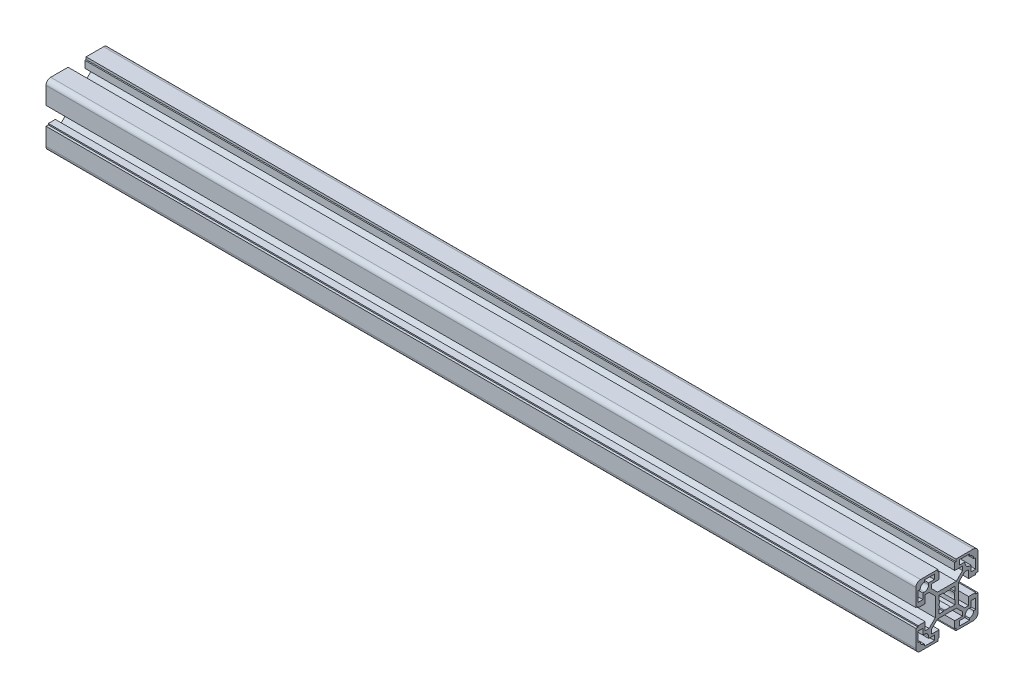
from build123d import *

# Parameters (mm, degrees)
BR_EXTRUDE_DEPTH      = 280
BR_EXTRUDE_DEPTH_BACK = 280


with BuildPart() as part:
    # Sketch2 → BR_Extrude (new body, two sides)
    with BuildSketch(Plane(origin=(0, 0, 0), x_dir=(0, 0, -1), z_dir=(1, 0, 0))) as br_extrude_sk:
        with BuildLine():
            Line((-10.05, 11.464213562), (-10.05, 14))
            Line((-10.05, 14), (-5, 14))
            Line((-5, 14), (-5, 18.5))
            Line((-5, 18.5), (-5.8, 18.5))
            Line((-5.8, 18.5), (-5.8, 20))
            Line((-5.8, 20), (-17, 20))
            ThreePointArc((-17, 20), (-19.121320344, 19.121320344), (-20, 17))
            Line((-20, 17), (-20, 5.8))
            Line((-20, 5.8), (-18.5, 5.8))
            Line((-18.5, 5.8), (-18.5, 5))
            Line((-18.5, 5), (-14, 5))
            Line((-14, 5), (-14, 10.05))
            Line((-14, 10.05), (-11.464213562, 10.05))
            Line((-11.464213562, 10.05), (-7.5, 6.085786438))
            Line((-7.5, 6.085786438), (-7.5, -6.085786438))
            Line((-7.5, -6.085786438), (-11.464213562, -10.05))
            Line((-11.464213562, -10.05), (-14, -10.05))
            Line((-14, -10.05), (-14, -5))
            Line((-14, -5), (-18.5, -5))
            Line((-18.5, -5), (-18.5, -5.8))
            Line((-18.5, -5.8), (-20, -5.8))
            Line((-20, -5.8), (-20, -17))
            ThreePointArc((-20, -17), (-19.121320344, -19.121320344), (-17, -20))
            Line((-17, -20), (-5.8, -20))
            Line((-5.8, -20), (-5.8, -18.5))
            Line((-5.8, -18.5), (-5, -18.5))
            Line((-5, -18.5), (-5, -14))
            Line((-5, -14), (-10.05, -14))
            Line((-10.05, -14), (-10.05, -11.464213562))
            Line((-10.05, -11.464213562), (-6.085786438, -7.5))
            Line((-6.085786438, -7.5), (6.085786438, -7.5))
            Line((6.085786438, -7.5), (10.05, -11.464213562))
            Line((10.05, -11.464213562), (10.05, -14))
            Line((10.05, -14), (5, -14))
            Line((5, -14), (5, -18.5))
            Line((5, -18.5), (5.8, -18.5))
            Line((5.8, -18.5), (5.8, -20))
            Line((5.8, -20), (17, -20))
            ThreePointArc((17, -20), (19.121320344, -19.121320344), (20, -17))
            Line((20, -17), (20, -5.8))
            Line((20, -5.8), (18.5, -5.8))
            Line((18.5, -5.8), (18.5, -5))
            Line((18.5, -5), (14, -5))
            Line((14, -5), (14, -10.05))
            Line((14, -10.05), (11.464213562, -10.05))
            Line((11.464213562, -10.05), (7.5, -6.085786438))
            Line((7.5, -6.085786438), (7.5, 6.085786438))
            Line((7.5, 6.085786438), (11.464213562, 10.05))
            Line((11.464213562, 10.05), (14, 10.05))
            Line((14, 10.05), (14, 5))
            Line((14, 5), (18.5, 5))
            Line((18.5, 5), (18.5, 5.8))
            Line((18.5, 5.8), (20, 5.8))
            Line((20, 5.8), (20, 17))
            ThreePointArc((20, 17), (19.121320344, 19.121320344), (17, 20))
            Line((17, 20), (5.8, 20))
            Line((5.8, 20), (5.8, 18.5))
            Line((5.8, 18.5), (5, 18.5))
            Line((5, 18.5), (5, 14))
            Line((5, 14), (10.05, 14))
            Line((10.05, 14), (10.05, 11.464213562))
            Line((10.05, 11.464213562), (6.085786438, 7.5))
            Line((6.085786438, 7.5), (-6.085786438, 7.5))
            Line((-6.085786438, 7.5), (-10.05, 11.464213562))
        make_face()
        with BuildLine():
            Line((8, 15.5), (8, 18.5))
            Line((8, 18.5), (14.5, 18.5))
            Line((14.5, 18.5), (14.5, 17.25))
            ThreePointArc((14.5, 17.25), (16.444543648, 16.444543648), (17.25, 14.5))
            Line((17.25, 14.5), (18.5, 14.5))
            Line((18.5, 14.5), (18.5, 8))
            Line((18.5, 8), (15.5, 8))
            Line((15.5, 8), (15.5, 11.75))
            Line((15.5, 11.75), (14.5, 11.75))
            ThreePointArc((14.5, 11.75), (12.555456352, 12.555456352), (11.75, 14.5))
            Line((11.75, 14.5), (11.75, 15.5))
            Line((11.75, 15.5), (8, 15.5))
        make_face(mode=Mode.SUBTRACT)
        with BuildLine():
            Line((8, -15.5), (11.75, -15.5))
            Line((11.75, -15.5), (11.75, -14.5))
            ThreePointArc((11.75, -14.5), (12.555456352, -12.555456352), (14.5, -11.75))
            Line((14.5, -11.75), (15.5, -11.75))
            Line((15.5, -11.75), (15.5, -8))
            Line((15.5, -8), (18.5, -8))
            Line((18.5, -8), (18.5, -14.5))
            Line((18.5, -14.5), (17.25, -14.5))
            ThreePointArc((17.25, -14.5), (16.444543648, -16.444543648), (14.5, -17.25))
            Line((14.5, -17.25), (14.5, -18.5))
            Line((14.5, -18.5), (8, -18.5))
            Line((8, -18.5), (8, -15.5))
        make_face(mode=Mode.SUBTRACT)
        with BuildLine():
            Line((-15.5, 8), (-18.5, 8))
            Line((-18.5, 8), (-18.5, 14.5))
            Line((-18.5, 14.5), (-17.25, 14.5))
            ThreePointArc((-17.25, 14.5), (-16.444543648, 16.444543648), (-14.5, 17.25))
            Line((-14.5, 17.25), (-14.5, 18.5))
            Line((-14.5, 18.5), (-8, 18.5))
            Line((-8, 18.5), (-8, 15.5))
            Line((-8, 15.5), (-11.75, 15.5))
            Line((-11.75, 15.5), (-11.75, 14.5))
            ThreePointArc((-11.75, 14.5), (-12.555456352, 12.555456352), (-14.5, 11.75))
            Line((-14.5, 11.75), (-15.5, 11.75))
            Line((-15.5, 11.75), (-15.5, 8))
        make_face(mode=Mode.SUBTRACT)
        with BuildLine():
            Line((-11.75, -14.5), (-11.75, -15.5))
            Line((-11.75, -15.5), (-8, -15.5))
            Line((-8, -15.5), (-8, -18.5))
            Line((-8, -18.5), (-14.5, -18.5))
            Line((-14.5, -18.5), (-14.5, -17.25))
            ThreePointArc((-14.5, -17.25), (-16.444543648, -16.444543648), (-17.25, -14.5))
            Line((-17.25, -14.5), (-18.5, -14.5))
            Line((-18.5, -14.5), (-18.5, -8))
            Line((-18.5, -8), (-15.5, -8))
            Line((-15.5, -8), (-15.5, -11.75))
            Line((-15.5, -11.75), (-14.5, -11.75))
            ThreePointArc((-14.5, -11.75), (-12.555456352, -12.555456352), (-11.75, -14.5))
        make_face(mode=Mode.SUBTRACT)
        with BuildLine():
            Line((-5.2, -5.2), (-5.2, -2.26102435))
            Line((-5.2, -2.26102435), (-4.585300372, -1.993745345))
            ThreePointArc((-4.585300372, -1.993745345), (-5, 0), (-4.585300372, 1.993745345))
            Line((-4.585300372, 1.993745345), (-5.2, 2.26102435))
            Line((-5.2, 2.26102435), (-5.2, 5.2))
            Line((-5.2, 5.2), (-2.26102435, 5.2))
            Line((-2.26102435, 5.2), (-1.993745345, 4.585300372))
            ThreePointArc((-1.993745345, 4.585300372), (0, 5), (1.993745345, 4.585300372))
            Line((1.993745345, 4.585300372), (2.26102435, 5.2))
            Line((2.26102435, 5.2), (5.2, 5.2))
            Line((5.2, 5.2), (5.2, 2.26102435))
            Line((5.2, 2.26102435), (4.585300372, 1.993745345))
            ThreePointArc((4.585300372, 1.993745345), (5, 0), (4.585300372, -1.993745345))
            Line((4.585300372, -1.993745345), (5.2, -2.26102435))
            Line((5.2, -2.26102435), (5.2, -5.2))
            Line((5.2, -5.2), (2.26102435, -5.2))
            Line((2.26102435, -5.2), (1.993745345, -4.585300372))
            ThreePointArc((1.993745345, -4.585300372), (0, -5), (-1.993745345, -4.585300372))
            Line((-1.993745345, -4.585300372), (-2.26102435, -5.2))
            Line((-2.26102435, -5.2), (-5.2, -5.2))
        make_face(mode=Mode.SUBTRACT)
    extrude(amount=BR_EXTRUDE_DEPTH)
    extrude(br_extrude_sk.sketch, amount=-BR_EXTRUDE_DEPTH_BACK)


solid = part.part
